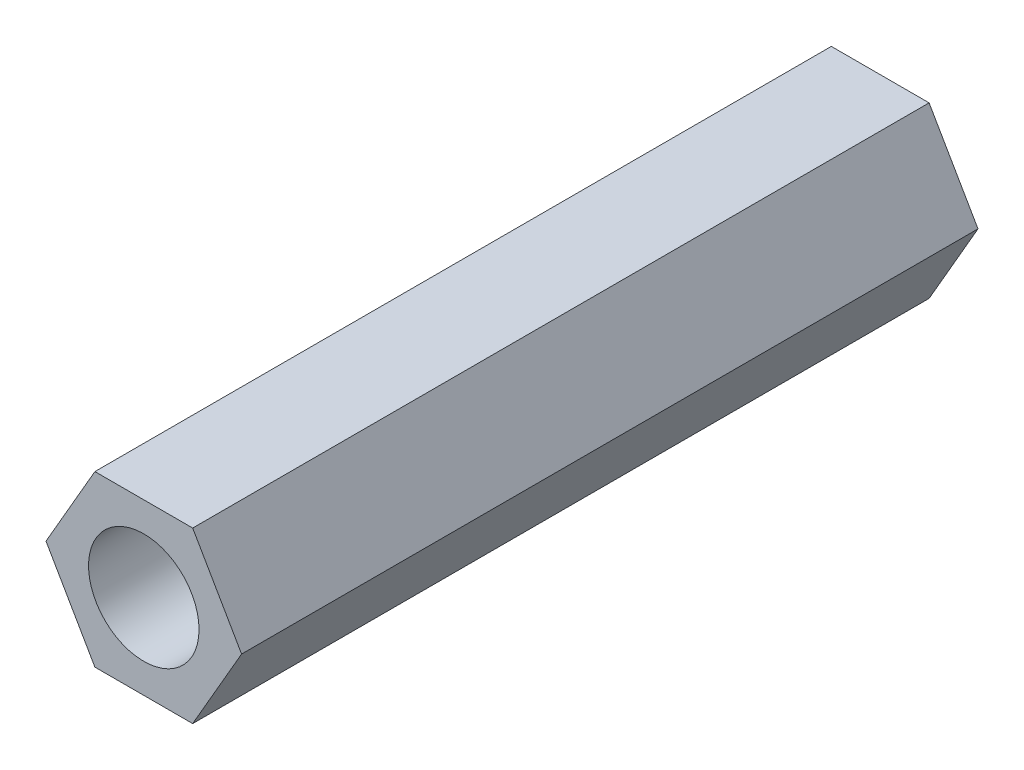
from build123d import *

# Parameters (mm, degrees)
SKETCH_1_R      = 1.5
EXTRUDE_1_DEPTH = 20


with BuildPart() as part:
    # 草图1 → 凸台-拉伸1 (new body)
    with BuildSketch(Plane.XY):
        Polygon((2.655811238, 0), (1.327905619, 2.3), (-1.327905619, 2.3), (-2.655811238, 0), (-1.327905619, -2.3), (1.327905619, -2.3), align=None)
        Circle(SKETCH_1_R, mode=Mode.SUBTRACT)
    extrude(amount=EXTRUDE_1_DEPTH)


solid = part.part
